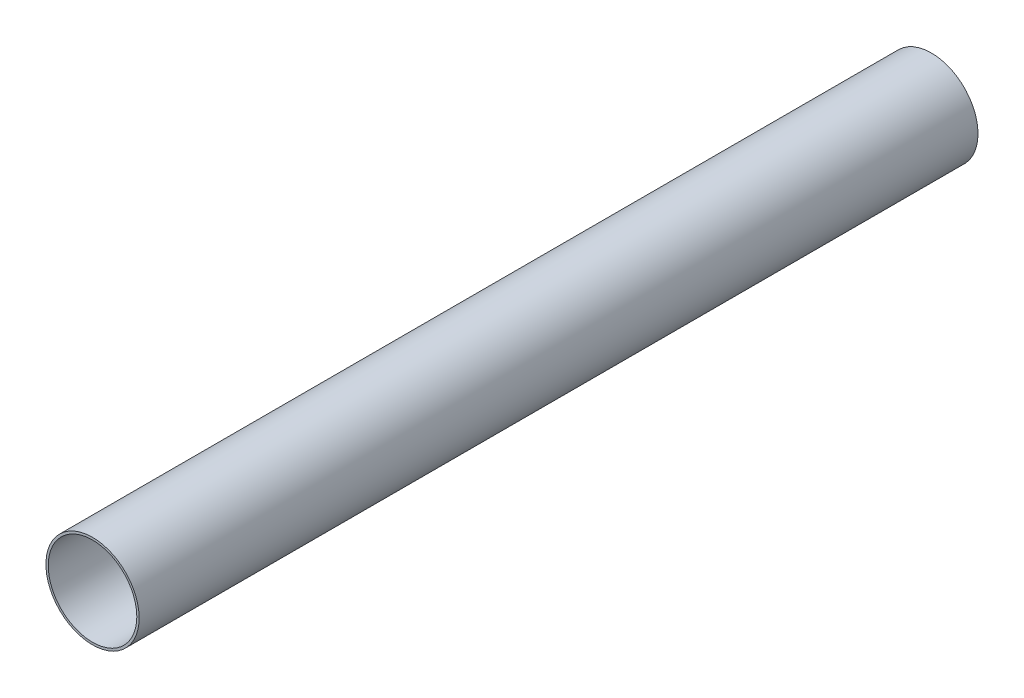
from build123d import *

# Parameters (mm, degrees)
PIPESKETCH_R    = 304.8
PIPESKETCH_R_2  = 289.7124
EXTRUSION_DEPTH = 5486.4


with BuildPart() as part:
    # PipeSketch → Extrusion (new body)
    with BuildSketch(Plane.XY):
        Circle(PIPESKETCH_R)
        Circle(PIPESKETCH_R_2, mode=Mode.SUBTRACT)
    extrude(amount=EXTRUSION_DEPTH)


solid = part.part
